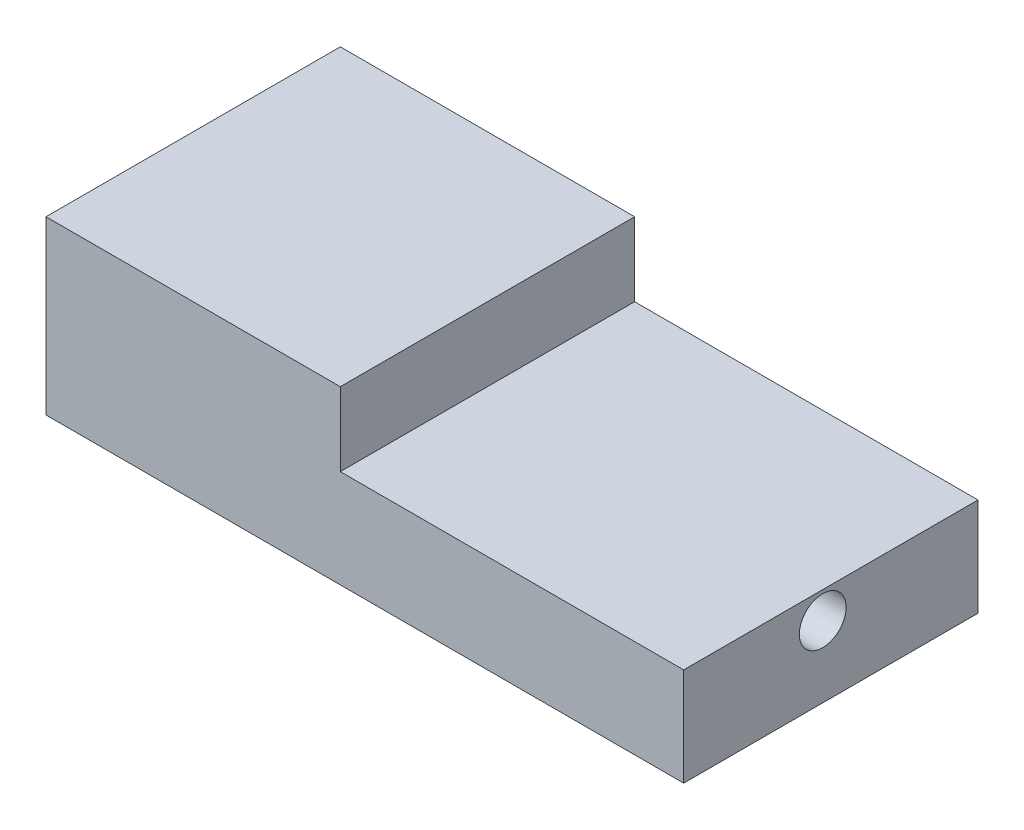
from build123d import *

# Parameters (mm, degrees)
SKETCH1_W           = 60
SKETCH1_H           = 20
BOSS_EXTRUDE1_DEPTH = 130
SKETCH2_W           = 60
SKETCH2_H           = 60
BOSS_EXTRUDE2_DEPTH = 15
SKETCH3_R           = 4.767204383
CUT_EXTRUDE1_DEPTH  = 200


with BuildPart() as part:
    # Sketch1 → Boss-Extrude1 (new body)
    with BuildSketch(Plane(origin=(0, 0, 0), x_dir=(0, 0, -1), z_dir=(1, 0, 0))):
        with Locations((1.866028708, -8.133971292)):
            Rectangle(SKETCH1_W, SKETCH1_H)
    extrude(amount=BOSS_EXTRUDE1_DEPTH)

    # Sketch2 → Boss-Extrude2 (add)
    with BuildSketch(Plane(origin=(0, 1.866028708, 0), x_dir=(1, 0, 0), z_dir=(0, 1, 0))):
        with Locations((30, 1.866028708)):
            Rectangle(SKETCH2_W, SKETCH2_H)
    extrude(amount=BOSS_EXTRUDE2_DEPTH)

    # Sketch3 → Cut-Extrude1 (cut)
    with BuildSketch(Plane(origin=(130, 0, 0), x_dir=(0, 0, -1), z_dir=(1, 0, 0))):
        with Locations((0.210093723, -3.611871182)):
            Circle(SKETCH3_R)
    extrude(amount=-CUT_EXTRUDE1_DEPTH, mode=Mode.SUBTRACT)


solid = part.part
